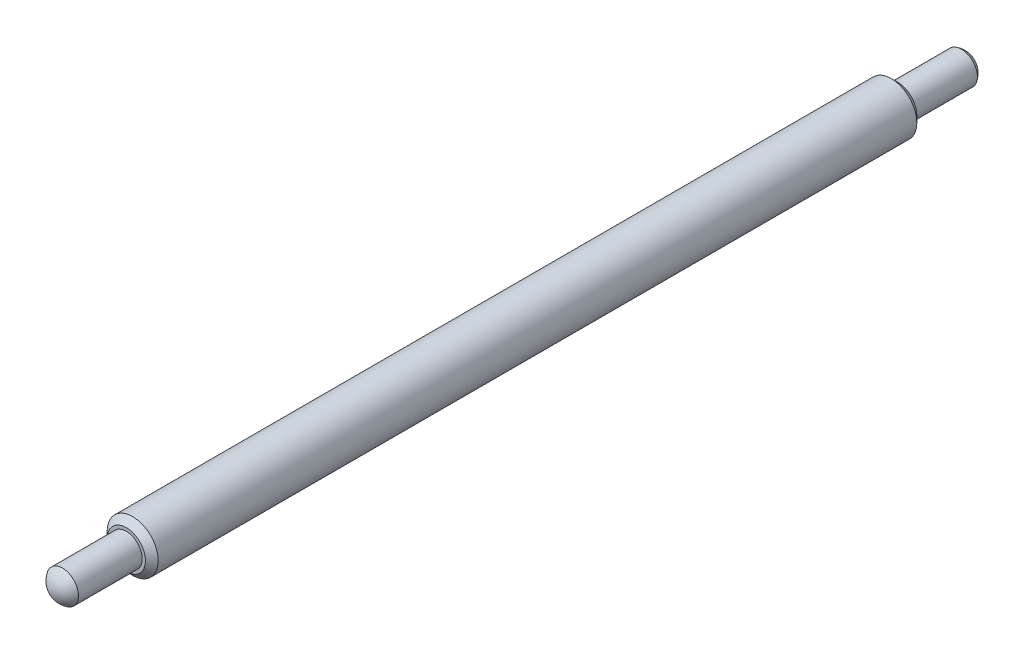
from build123d import *

# Parameters (mm, degrees)
CHAMFER1_SIZE = 0.5


with BuildPart() as part:
    # Sketch2 → Revolve1 (revolve)
    with BuildSketch(Plane(origin=(0, 0, 0), x_dir=(0, 0, -1), z_dir=(1, 0, 0))):
        with BuildLine():
            Line((65.5, 0), (-5, 0))
            Line((-5, 0), (-5.7, 0))
            ThreePointArc((-5.7, 0), (-5.513084713, -0.716327439), (-5, -1.25))
            Line((-5, -1.25), (0, -1.25))
            Line((0, -1.25), (0, -2))
            Line((0, -2), (60.5, -2))
            Line((60.5, -2), (60.5, -1.25))
            Line((60.5, -1.25), (65.5, -1.25))
            ThreePointArc((65.5, -1.25), (66.013084713, -0.716327439), (66.2, 0))
            Line((66.2, 0), (65.5, 0))
        make_face()
    revolve(axis=Axis((0, 0, -65.5), (0, 0, 1)))

    # Chamfer1
    chamfer1_edges = [part.edges().sort_by_distance(p)[0] for p in [
        (0, 2, -60.5),
        (0, 2, 0),
    ]]
    chamfer(chamfer1_edges, length=CHAMFER1_SIZE)


solid = part.part
